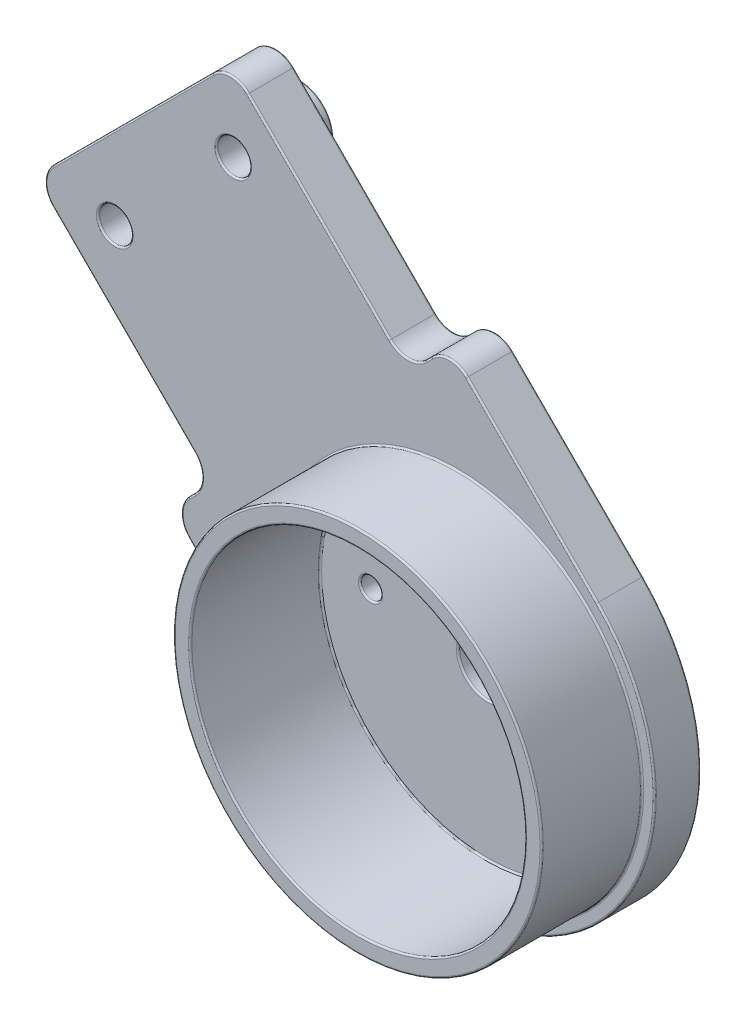
from build123d import *

# Parameters (mm, degrees)
SKETCH6_R           = 10
SKETCH6_R_2         = 1
BOSS_EXTRUDE1_DEPTH = 2.75
SKETCH7_R           = 10
BOSS_EXTRUDE2_DEPTH = 1
SKETCH8_R           = 11
SKETCH8_R_2         = 10
BOSS_EXTRUDE3_DEPTH = 7.75
FILLET1_R           = 1.5
SKETCH11_R          = 2
SKETCH11_R_2        = 1
BOSS_EXTRUDE4_DEPTH = 1.25
SKETCH12_R          = 1.75
CUT_EXTRUDE1_DEPTH  = 1
SKETCH13_R          = 3.45
SKETCH13_R_2        = 1.75
BOSS_EXTRUDE5_DEPTH = 4.25
SKETCH14_R          = 0.625
CUT_EXTRUDE2_DEPTH  = 1
FILLET2_R           = 0.1


with BuildPart() as part:
    # Sketch6 → Boss-Extrude1 (new body)
    with BuildSketch(Plane.XY):
        with BuildLine():
            Line((86.388194462, 25.279067427), (74.720932573, 13.611805538))
            Line((74.720932573, 13.611805538), (85.32753429, 3.00520382))
            Line((85.32753429, 3.00520382), (82.852660556, 0.530330086))
            Line((82.852660556, 0.530330086), (91.691495321, -8.308504679))
            ThreePointArc((91.691495321, -8.308504679), (108.308504679, -8.308504679), (108.308504679, 8.308504679))
            Line((108.308504679, 8.308504679), (99.469669914, 17.147339444))
            Line((99.469669914, 17.147339444), (96.99479618, 14.67246571))
            Line((96.99479618, 14.67246571), (86.388194462, 25.279067427))
        make_face()
        with Locations((100, 0)):
            Circle(SKETCH6_R, mode=Mode.SUBTRACT)
        with Locations((86.564971157, 20.506096654)):
            Circle(SKETCH6_R_2, mode=Mode.SUBTRACT)
        with Locations((79.493903346, 13.435028843)):
            Circle(SKETCH6_R_2, mode=Mode.SUBTRACT)
    extrude(amount=BOSS_EXTRUDE1_DEPTH)



with BuildPart() as body_2:
    # Sketch7 → Boss-Extrude2 (new body)
    with BuildSketch(Plane(origin=(0, 0, 0), x_dir=(-1, 0, 0), z_dir=(0, 0, -1))):
        with Locations((-100, 0)):
            Circle(SKETCH7_R)
    extrude(amount=-BOSS_EXTRUDE2_DEPTH)


with BuildPart() as part_1:
    add(part.part)

    add(body_2.part)  # Boss-Extrude3 merges body 2
    # Sketch8 → Boss-Extrude3 (add)
    with BuildSketch(Plane.XY.offset(1)):
        with Locations((100, 0)):
            Circle(SKETCH8_R)
        with Locations((100, 0)):
            Circle(SKETCH8_R_2, mode=Mode.SUBTRACT)
    extrude(amount=BOSS_EXTRUDE3_DEPTH)

    # Fillet1
    fillet1_edges = [part_1.edges().sort_by_distance(p)[0] for p in [
        (96.99479618, 14.67246571, 1.375),
        (99.469669914, 17.147339444, 1.375),
        (82.852660556, 0.530330086, 1.375),
        (85.32753429, 3.00520382, 1.375),
        (74.720932573, 13.611805538, 1.375),
        (86.388194462, 25.279067427, 1.375),
    ]]
    fillet(fillet1_edges, radius=FILLET1_R)

    # Sketch11 → Boss-Extrude4 (add)
    with BuildSketch(Plane(origin=(0, 0, 0), x_dir=(-1, 0, 0), z_dir=(0, 0, -1))):
        with Locations((-86.564971157, 20.506096654)):
            Circle(SKETCH11_R)
        with Locations((-86.564971157, 20.506096654)):
            Circle(SKETCH11_R_2, mode=Mode.SUBTRACT)
        with Locations((-79.493903346, 13.435028843)):
            Circle(SKETCH11_R)
        with Locations((-79.493903346, 13.435028843)):
            Circle(SKETCH11_R_2, mode=Mode.SUBTRACT)
    extrude(amount=BOSS_EXTRUDE4_DEPTH)

    # Sketch12 → Cut-Extrude1 (cut)
    with BuildSketch(Plane(origin=(0, 0, 0), x_dir=(-1, 0, 0), z_dir=(0, 0, -1))):
        with Locations((-100, 0)):
            Circle(SKETCH12_R)
    extrude(amount=-CUT_EXTRUDE1_DEPTH, mode=Mode.SUBTRACT)

    # Sketch13 → Boss-Extrude5 (add)
    with BuildSketch(Plane(origin=(0, 0, 0), x_dir=(-1, 0, 0), z_dir=(0, 0, -1))):
        with Locations((-100, 0)):
            Circle(SKETCH13_R)
        with Locations((-100, 0)):
            Circle(SKETCH13_R_2, mode=Mode.SUBTRACT)
    extrude(amount=BOSS_EXTRUDE5_DEPTH)

    # Sketch14 → Cut-Extrude2 (cut)
    with BuildSketch(Plane(origin=(0, 0, 0), x_dir=(-1, 0, 0), z_dir=(0, 0, -1))):
        with Locations((-93.020352093, 0.533399557)):
            Circle(SKETCH14_R)
        with Locations((-103.027886387, -6.311252176)):
            Circle(SKETCH14_R)
        with Locations((-103.951761521, 5.777852619)):
            Circle(SKETCH14_R)
    extrude(amount=-CUT_EXTRUDE2_DEPTH, mode=Mode.SUBTRACT)

    # Fillet2
    fillet2_edges = [part_1.edges().sort_by_distance(p)[0] for p in [
        (81.493903346, 13.435028843, -1.25),
        (80.493903346, 13.435028843, -1.25),
        (101.75, 0, 1),
        (103.45, 0, 0),
        (103.45, 0, -4.25),
        (101.75, 0, -4.25),
        (93.645352093, 0.533399557, 0),
        (93.645352093, 0.533399557, 1),
        (103.652886387, -6.311252176, 0),
        (103.652886387, -6.311252176, 1),
        (104.576761521, 5.777852619, 0),
        (104.576761521, 5.777852619, 1),
        (108.308504679, -8.308504679, 2.75),
        (85.564971157, 20.506096654, 2.75),
        (104.419417382, 12.197591975, 2.75),
        (78.493903346, 13.435028843, 2.75),
        (89, 0, 2.75),
        (89, 0, 8.75),
        (90, 0, 8.75),
        (90, 0, 1),
        (91.691495321, 19.975766569, 0),
        (91.691495321, 19.975766569, 2.75),
        (98.232233047, 15.909902577, 0),
        (98.232233047, 15.909902577, 2.75),
        (87.802408025, -4.419417382, 0),
        (84.090097423, 1.767766953, 0),
        (80.024233431, 8.308504679, 0),
        (80.554563517, 19.445436483, 0),
        (86.388194462, 24.657747084, 0),
        (75.342252916, 13.611805538, 0),
        (83.4739809, 0.530330086, 0),
        (99.469669914, 16.5260191, 0),
        (80.554563517, 19.445436483, 2.75),
        (80.024233431, 8.308504679, 2.75),
        (84.090097423, 1.767766953, 2.75),
        (87.802408025, -4.419417382, 2.75),
        (86.388194462, 24.657747084, 2.75),
        (75.342252916, 13.611805538, 2.75),
        (83.4739809, 0.530330086, 2.75),
        (99.469669914, 16.5260191, 2.75),
        (96.99479618, 15.293786053, 0),
        (96.99479618, 15.293786053, 2.75),
        (84.706213947, 3.00520382, 0),
        (84.706213947, 3.00520382, 2.75),
        (104.419417382, 12.197591975, 0),
        (88.564971157, 20.506096654, 0),
        (108.308504679, -8.308504679, 0),
        (88.564971157, 20.506096654, -1.25),
        (87.564971157, 20.506096654, -1.25),
        (81.493903346, 13.435028843, 0),
    ]]
    fillet(fillet2_edges, radius=FILLET2_R)


solid = part_1.part
